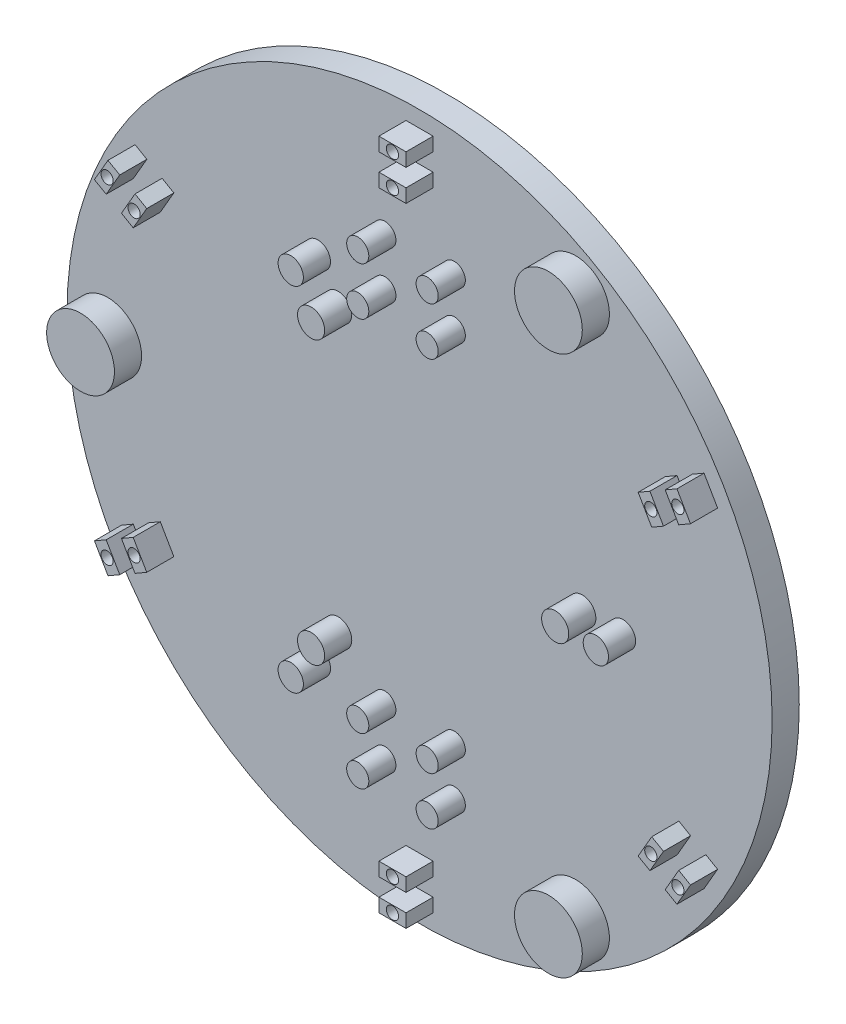
from build123d import *

# Parameters (mm, degrees)
SKETCH1_R           = 33.02
BOSS_EXTRUDE1_DEPTH = 2.54
SKETCH2_R           = 3.175
BOSS_EXTRUDE2_DEPTH = 2.54
CIRPATTERN1_COUNT   = 3
SKETCH3_W           = 2.54
SKETCH3_H           = 1.27
SKETCH3_R           = 0.5715
BOSS_EXTRUDE3_DEPTH = 2.54
CIRPATTERN8_COUNT   = 6
SKETCH4_R           = 1.036302298
BOSS_EXTRUDE4_DEPTH = 2.54
SKETCH5_R           = 1.269883707
SKETCH5_R_2         = 1.184340282
BOSS_EXTRUDE5_DEPTH = 2.54
CIRPATTERN9_COUNT   = 3


with BuildPart() as part:
    # Sketch1 → Boss-Extrude1 (new body)
    with BuildSketch(Plane.XY):
        Circle(SKETCH1_R)
    extrude(amount=BOSS_EXTRUDE1_DEPTH)

    # Sketch2 → Boss-Extrude2 (add)
    with BuildSketch(Plane.XY.offset(2.54)):
        with Locations((14.605, 25.296602045)):
            Circle(SKETCH2_R)
    boss_extrude2 = extrude(amount=BOSS_EXTRUDE2_DEPTH)

    # CirPattern1: Boss-Extrude2 ×3 about axis
    cirpattern1_axis = Axis((0, 0, 34.648246475), (0, 0, -1))
    for i in range(1, CIRPATTERN1_COUNT):
        add(boss_extrude2.rotate(cirpattern1_axis, i * 360 / CIRPATTERN1_COUNT))

    # Sketch3 → Boss-Extrude3 (add)
    # profile 1 of 2: a face of its own
    with BuildSketch(Plane.XY.offset(2.54)):
        with Locations((0, -27.94)):
            Rectangle(SKETCH3_W, SKETCH3_H)
        with Locations((0, -27.94)):
            Circle(SKETCH3_R, mode=Mode.SUBTRACT)
    # profile 2 of 2: a face of its own
    with BuildSketch(Plane.XY.offset(2.54)):
        with Locations((0, -30.861)):
            Rectangle(SKETCH3_W, SKETCH3_H)
        with Locations((0, -30.861)):
            Circle(SKETCH3_R, mode=Mode.SUBTRACT)
    boss_extrude3 = extrude(amount=BOSS_EXTRUDE3_DEPTH)

    # CirPattern8: Boss-Extrude3 ×6 about axis
    cirpattern8_axis = Axis((0, 0, 34.648246475), (0, 0, -1))
    for i in range(1, CIRPATTERN8_COUNT):
        add(boss_extrude3.rotate(cirpattern8_axis, i * 360 / CIRPATTERN8_COUNT))

    # Sketch4 → Boss-Extrude4 (add)
    with BuildSketch(Plane.XY.offset(2.54)):
        with Locations((-3.2512, 21.2979)):
            Circle(SKETCH4_R)
        with Locations((-3.2512, -16.8021)):
            Circle(SKETCH4_R)
        with Locations((3.2512, 21.2979)):
            Circle(SKETCH4_R)
        with Locations((3.2512, 16.8021)):
            Circle(SKETCH4_R)
        with Locations((-3.2512, 16.8021)):
            Circle(SKETCH4_R)
        with Locations((3.2512, -16.8021)):
            Circle(SKETCH4_R)
        with Locations((3.2512, -21.2979)):
            Circle(SKETCH4_R)
        with Locations((-3.2512, -21.2979)):
            Circle(SKETCH4_R)
    extrude(amount=BOSS_EXTRUDE4_DEPTH)

    # Sketch5 → Boss-Extrude5 (add)
    with BuildSketch(Plane.XY.offset(2.54)):
        with Locations((15.24, 0)):
            Circle(SKETCH5_R)
        with Locations((19.05, 0)):
            Circle(SKETCH5_R_2)
    boss_extrude5 = extrude(amount=BOSS_EXTRUDE5_DEPTH)

    # CirPattern9: Boss-Extrude5 ×3 about axis
    cirpattern9_axis = Axis((0, 0, 34.648246475), (0, 0, -1))
    for i in range(1, CIRPATTERN9_COUNT):
        add(boss_extrude5.rotate(cirpattern9_axis, i * 360 / CIRPATTERN9_COUNT))


solid = part.part
